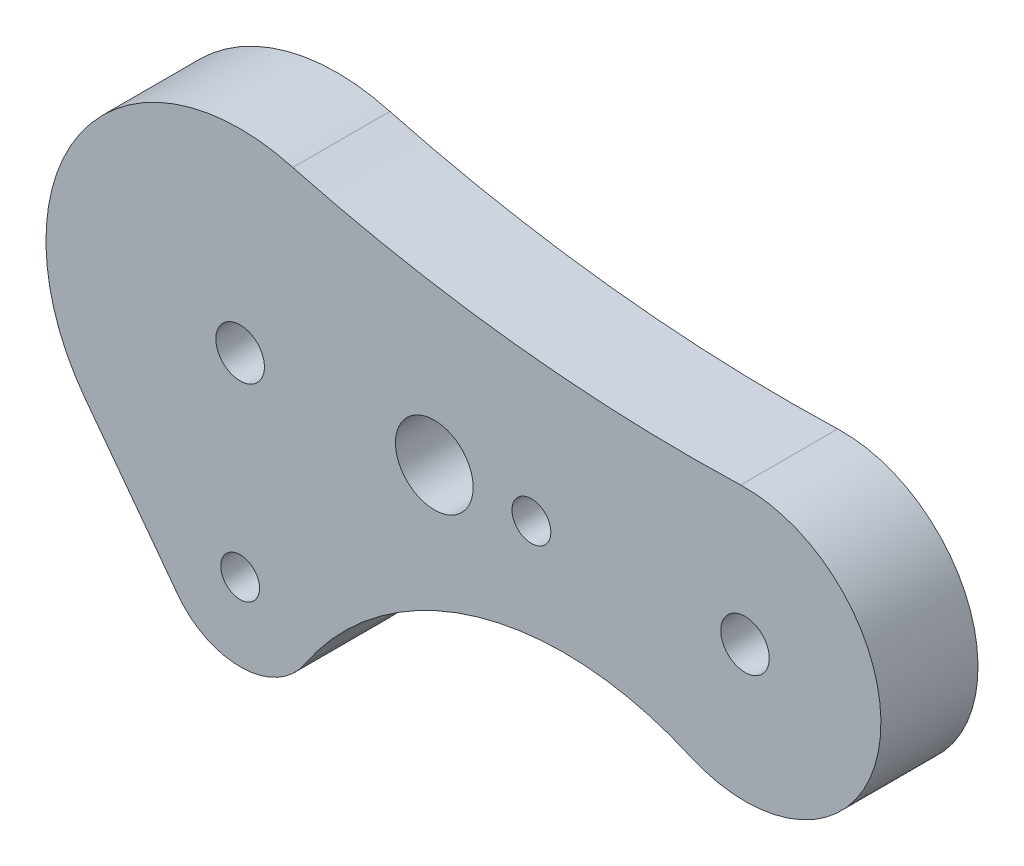
from build123d import *

# Parameters (mm, degrees)
SKETCH1_R           = 1.25
SKETCH1_R_2         = 2
SKETCH1_R_3         = 1
BOSS_EXTRUDE1_DEPTH = 5


with BuildPart() as part:
    # Sketch1 → Boss-Extrude1 (new body)
    with BuildSketch(Plane.XY):
        with BuildLine():
            Line((-8, -6), (-3.2, -12.4))
            ThreePointArc((-3.2, -12.4), (0.118790152, -13.998235723), (3.336840869, -12.205786258))
            ThreePointArc((3.336840869, -12.205786258), (12.188123784, -5.673630591), (23.164757844, -6.400109524))
            ThreePointArc((23.164757844, -6.400109524), (32.870759027, -1.338906415), (25.775337581, 6.996393842))
            ThreePointArc((25.775337581, 6.996393842), (14.14827012, 7.469801361), (2.712885779, 9.624980559))
            ThreePointArc((2.712885779, 9.624980559), (-8.247629875, 5.654785711), (-8, -6))
        make_face()
        Circle(SKETCH1_R, mode=Mode.SUBTRACT)
        with Locations((26, 0)):
            Circle(SKETCH1_R, mode=Mode.SUBTRACT)
        with Locations((10, 0)):
            Circle(SKETCH1_R_2, mode=Mode.SUBTRACT)
        with Locations((15, 0)):
            Circle(SKETCH1_R_3, mode=Mode.SUBTRACT)
        with Locations((0, -10)):
            Circle(SKETCH1_R_3, mode=Mode.SUBTRACT)
    extrude(amount=BOSS_EXTRUDE1_DEPTH)


solid = part.part
